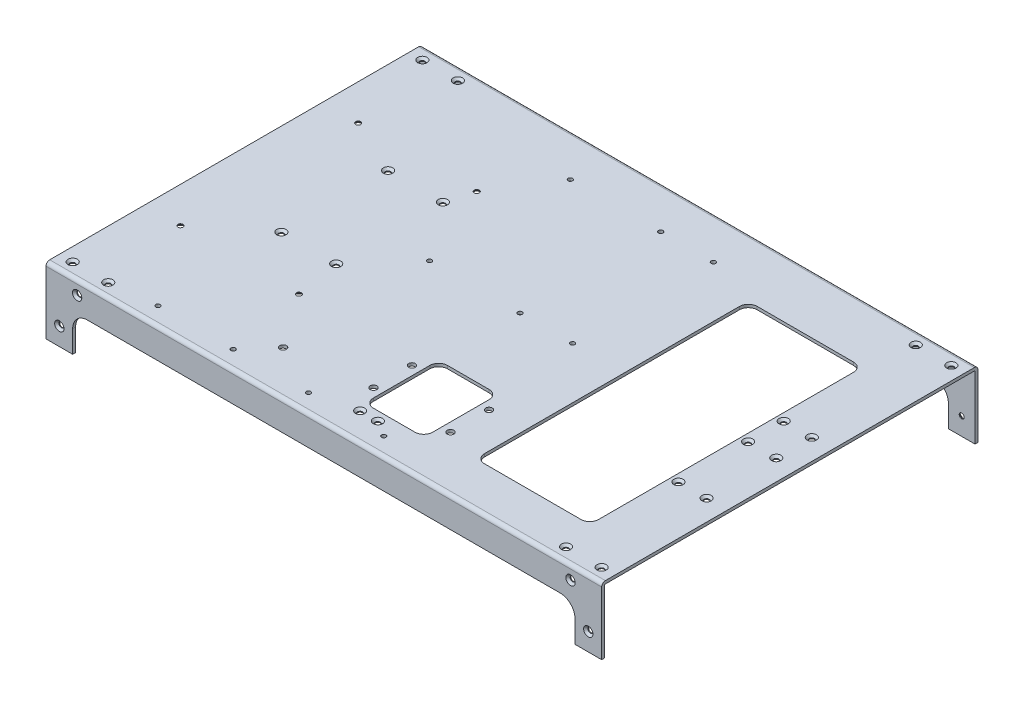
from build123d import *

# Parameters (mm, degrees)
BOSS_EXTRUDE1_DEPTH                             = 187.5
CUT_EXTRUDE1_DEPTH                              = 255
CUT_EXTRUDE4_DEPTH                              = 10
SKETCH6_R                                       = 1.5
CUT_EXTRUDE5_DEPTH                              = 255
SKETCH9_R                                       = 1.5
CUT_EXTRUDE8_DEPTH                              = 10
SKETCH19_R                                      = 1.5
CUT_EXTRUDE9_DEPTH                              = 10
SKETCH20_R                                      = 1.75
CUT_EXTRUDE10_DEPTH                             = 10
CSK_FOR_M3_FLAT_HEAD_MACHINE_SCREW1_D           = 3.4
CSK_FOR_M3_FLAT_HEAD_MACHINE_SCREW1_DEPTH       = 10
CSK_FOR_M3_FLAT_HEAD_MACHINE_SCREW1_CSINK_D     = 6.3
CSK_FOR_M3_FLAT_HEAD_MACHINE_SCREW1_CSINK_ANGLE = 90
CSK_FOR_M3_FLAT_HEAD_MACHINE_SCREW1_TIP         = 1.021463052
CSK_FOR_M3_FLAT_HEAD_MACHINE_SCREW2_D           = 3.4
CSK_FOR_M3_FLAT_HEAD_MACHINE_SCREW2_DEPTH       = 10
CSK_FOR_M3_FLAT_HEAD_MACHINE_SCREW2_CSINK_D     = 6.3
CSK_FOR_M3_FLAT_HEAD_MACHINE_SCREW2_CSINK_ANGLE = 90
CSK_FOR_M3_FLAT_HEAD_MACHINE_SCREW2_TIP         = 1.021463052
CSK_FOR_M3_FLAT_HEAD_MACHINE_SCREW3_D           = 3.4
CSK_FOR_M3_FLAT_HEAD_MACHINE_SCREW3_DEPTH       = 10
CSK_FOR_M3_FLAT_HEAD_MACHINE_SCREW3_CSINK_D     = 6.3
CSK_FOR_M3_FLAT_HEAD_MACHINE_SCREW3_CSINK_ANGLE = 90
CSK_FOR_M3_FLAT_HEAD_MACHINE_SCREW3_TIP         = 1.021463052
SKETCH28_R                                      = 2.25
CUT_EXTRUDE11_DEPTH                             = 10
CSK_FOR_M3_FLAT_HEAD_MACHINE_SCREW4_D           = 3.4
CSK_FOR_M3_FLAT_HEAD_MACHINE_SCREW4_DEPTH       = 10
CSK_FOR_M3_FLAT_HEAD_MACHINE_SCREW4_CSINK_D     = 6.3
CSK_FOR_M3_FLAT_HEAD_MACHINE_SCREW4_CSINK_ANGLE = 90
CSK_FOR_M3_FLAT_HEAD_MACHINE_SCREW4_TIP         = 1.021463052
SKETCH31_R                                      = 2.25
SKETCH31_R_2                                    = 1.5
CUT_EXTRUDE12_DEPTH                             = 10
CSK_FOR_M3_FLAT_HEAD_MACHINE_SCREW5_D           = 3.4
CSK_FOR_M3_FLAT_HEAD_MACHINE_SCREW5_DEPTH       = 10
CSK_FOR_M3_FLAT_HEAD_MACHINE_SCREW5_CSINK_D     = 6.3
CSK_FOR_M3_FLAT_HEAD_MACHINE_SCREW5_CSINK_ANGLE = 90
CSK_FOR_M3_FLAT_HEAD_MACHINE_SCREW5_TIP         = 1.021463052


with BuildPart() as part:
    # Sketch1 → Boss-Extrude1 (new body, symmetric)
    with BuildSketch(Plane(origin=(0, 0, 0), x_dir=(0, 0, -1), z_dir=(1, 0, 0))):
        with BuildLine():
            Line((125, -100.5), (127, -100.5))
            Line((127, -100.5), (127, -2.5))
            ThreePointArc((127, -2.5), (126.267766953, -0.732233047), (124.5, 0))
            Line((124.5, 0), (-124.5, 0))
            ThreePointArc((-124.5, 0), (-126.267766953, -0.732233047), (-127, -2.5))
            Line((-127, -2.5), (-127, -100.5))
            Line((-127, -100.5), (-125, -100.5))
            Line((-125, -100.5), (-125, -2.5))
            ThreePointArc((-125, -2.5), (-124.853553391, -2.146446609), (-124.5, -2))
            Line((-124.5, -2), (124.5, -2))
            ThreePointArc((124.5, -2), (124.853553391, -2.146446609), (125, -2.5))
            Line((125, -2.5), (125, -100.5))
        make_face()
    extrude(amount=BOSS_EXTRUDE1_DEPTH, both=True)

    # Sketch2 → Cut-Extrude1 (cut, through all)
    with BuildSketch(Plane.XY.offset(127)):
        with BuildLine():
            Line((187.5, -45), (187.5, -100.5))
            Line((187.5, -100.5), (-187.5, -100.5))
            Line((-187.5, -100.5), (-187.5, -45))
            Line((-187.5, -45), (-169.5, -45))
            Line((-169.5, -45), (-169.5, -30))
            ThreePointArc((-169.5, -30), (-166.571067812, -22.928932188), (-159.5, -20))
            Line((-159.5, -20), (159.5, -20))
            ThreePointArc((159.5, -20), (166.571067812, -22.928932188), (169.5, -30))
            Line((169.5, -30), (169.5, -45))
            Line((169.5, -45), (187.5, -45))
        make_face()
    extrude(amount=-CUT_EXTRUDE1_DEPTH, mode=Mode.SUBTRACT)

    # Sketch5 → Cut-Extrude4 (cut)
    with BuildSketch(Plane.XZ.offset(2)):
        with BuildLine():
            Line((78.5, 97), (143.5, 97))
            ThreePointArc((143.5, 97), (147.742640687, 95.242640687), (149.5, 91))
            Line((149.5, 91), (149.5, -81))
            ThreePointArc((149.5, -81), (147.742640687, -85.242640687), (143.5, -87))
            Line((143.5, -87), (78.5, -87))
            ThreePointArc((78.5, -87), (74.257359313, -85.242640687), (72.5, -81))
            Line((72.5, -81), (72.5, 91))
            ThreePointArc((72.5, 91), (74.257359313, 95.242640687), (78.5, 97))
        make_face()
    extrude(amount=-CUT_EXTRUDE4_DEPTH, mode=Mode.SUBTRACT)

    # Sketch6 → Cut-Extrude5 (cut, through all)
    with BuildSketch(Plane(origin=(0, 0, -127), x_dir=(-1, 0, 0), z_dir=(0, 0, -1))):
        with Locations((-178.5, -33)):
            Circle(SKETCH6_R)
        with Locations((-166.5, -9)):
            Circle(SKETCH6_R)
        with Locations((166.5, -9)):
            Circle(SKETCH6_R)
        with Locations((178.5, -33)):
            Circle(SKETCH6_R)
    extrude(amount=-CUT_EXTRUDE5_DEPTH, mode=Mode.SUBTRACT)

    # Sketch9 → Cut-Extrude8 (cut)
    with BuildSketch(Plane(origin=(0, 0, 0), x_dir=(1, 0, 0), z_dir=(0, 1, 0))):
        with Locations(Location((-178.5, 118, 0), (0, 0, 270))):  # turned: the seam where the file's is
            Circle(SKETCH9_R)
        with Locations(Location((-154.5, 118, 0), (0, 0, 270))):  # turned: the seam where the file's is
            Circle(SKETCH9_R)
        with Locations(Location((154.5, 118, 0), (0, 0, 270))):  # turned: the seam where the file's is
            Circle(SKETCH9_R)
        with Locations(Location((178.5, 118, 0), (0, 0, 270))):  # turned: the seam where the file's is
            Circle(SKETCH9_R)
        with Locations(Location((178.5, -118, 0), (0, 0, 270))):  # turned: the seam where the file's is
            Circle(SKETCH9_R)
        with Locations(Location((154.5, -118, 0), (0, 0, 270))):  # turned: the seam where the file's is
            Circle(SKETCH9_R)
        with Locations(Location((-154.5, -118, 0), (0, 0, 270))):  # turned: the seam where the file's is
            Circle(SKETCH9_R)
        with Locations(Location((-178.5, -118, 0), (0, 0, 270))):  # turned: the seam where the file's is
            Circle(SKETCH9_R)
        with Locations(Location((-125.5, 41.85, 0), (0, 0, 270))):  # turned: the seam where the file's is
            Circle(SKETCH9_R)
        with Locations(Location((-88.5, 41.85, 0), (0, 0, 270))):  # turned: the seam where the file's is
            Circle(SKETCH9_R)
        with Locations(Location((-125.5, -30.15, 0), (0, 0, 270))):  # turned: the seam where the file's is
            Circle(SKETCH9_R)
        with Locations(Location((-88.5, -30.15, 0), (0, 0, 270))):  # turned: the seam where the file's is
            Circle(SKETCH9_R)
        with Locations(Location((154.5, 28.85, 0), (0, 0, 270))):  # turned: the seam where the file's is
            Circle(SKETCH9_R)
        with Locations(Location((173.5, 4.85, 0), (0, 0, 270))):  # turned: the seam where the file's is
            Circle(SKETCH9_R)
        with Locations(Location((154.5, 4.85, 0), (0, 0, 270))):  # turned: the seam where the file's is
            Circle(SKETCH9_R)
        with Locations(Location((173.5, 28.85, 0), (0, 0, 270))):  # turned: the seam where the file's is
            Circle(SKETCH9_R)
        with Locations(Location((154.5, -42.15, 0), (0, 0, 270))):  # turned: the seam where the file's is
            Circle(SKETCH9_R)
        with Locations(Location((173.5, -42.15, 0), (0, 0, 270))):  # turned: the seam where the file's is
            Circle(SKETCH9_R)
    extrude(amount=-CUT_EXTRUDE8_DEPTH, mode=Mode.SUBTRACT)

    # Sketch19 → Cut-Extrude9 (cut)
    with BuildSketch(Plane(origin=(0, 0, 0), x_dir=(1, 0, 0), z_dir=(0, 1, 0))):
        with Locations(Location((2.31, 98.065, 0), (0, 0, 270))):  # turned: the seam where the file's is
            Circle(SKETCH19_R)
        with Locations(Location((-58.69, 98.065, 0), (0, 0, 270))):  # turned: the seam where the file's is
            Circle(SKETCH19_R)
        with Locations(Location((37.83, 98.065, 0), (0, 0, 270))):  # turned: the seam where the file's is
            Circle(SKETCH19_R)
        with Locations(Location((-58.69, 3.065, 0), (0, 0, 270))):  # turned: the seam where the file's is
            Circle(SKETCH19_R)
        with Locations(Location((37.83, 3.065, 0), (0, 0, 270))):  # turned: the seam where the file's is
            Circle(SKETCH19_R)
        with Locations(Location((2.31, 3.065, 0), (0, 0, 270))):  # turned: the seam where the file's is
            Circle(SKETCH19_R)
        with Locations(Location((-163.3, 59.5, 0), (0, 0, 270))):  # turned: the seam where the file's is
            Circle(SKETCH19_R)
        with Locations(Location((-163.3, -60.5, 0), (0, 0, 270))):  # turned: the seam where the file's is
            Circle(SKETCH19_R)
        with Locations(Location((-83.3, -60.5, 0), (0, 0, 270))):  # turned: the seam where the file's is
            Circle(SKETCH19_R)
        with Locations(Location((-83.3, 59.5, 0), (0, 0, 270))):  # turned: the seam where the file's is
            Circle(SKETCH19_R)
        with Locations(Location((-124.1, -114.8527, 0), (0, 0, 270))):  # turned: the seam where the file's is
            Circle(SKETCH19_R)
        with Locations(Location((-73.3, -114.8527, 0), (0, 0, 270))):  # turned: the seam where the file's is
            Circle(SKETCH19_R)
        with Locations(Location((-22.5, -114.8527, 0), (0, 0, 270))):  # turned: the seam where the file's is
            Circle(SKETCH19_R)
        with Locations(Location((28.3, -114.8527, 0), (0, 0, 270))):  # turned: the seam where the file's is
            Circle(SKETCH19_R)
    extrude(amount=-CUT_EXTRUDE9_DEPTH, mode=Mode.SUBTRACT)

    # Sketch20 → Cut-Extrude10 (cut)
    with BuildSketch(Plane(origin=(0, 0, -127), x_dir=(-1, 0, 0), z_dir=(0, 0, -1))):
        with Locations((-39.5, -8)):
            Circle(SKETCH20_R)
        with Locations((47.5, -8)):
            Circle(SKETCH20_R)
        with Locations((134.5, -8)):
            Circle(SKETCH20_R)
    extrude(amount=-CUT_EXTRUDE10_DEPTH, mode=Mode.SUBTRACT)

    # CSK for M3 Flat Head Machine Screw1
    with Locations(Plane.XY.offset(127)):
        with Locations((-166.5, -9), (166.5, -9), (178.5, -33), (-178.5, -33)):
            CounterSinkHole(CSK_FOR_M3_FLAT_HEAD_MACHINE_SCREW1_D / 2, CSK_FOR_M3_FLAT_HEAD_MACHINE_SCREW1_CSINK_D / 2, depth=CSK_FOR_M3_FLAT_HEAD_MACHINE_SCREW1_DEPTH, counter_sink_angle=CSK_FOR_M3_FLAT_HEAD_MACHINE_SCREW1_CSINK_ANGLE)
            with Locations((0, 0, -(CSK_FOR_M3_FLAT_HEAD_MACHINE_SCREW1_DEPTH + CSK_FOR_M3_FLAT_HEAD_MACHINE_SCREW1_TIP / 2))):  # 118° drill point
                Cone(0, CSK_FOR_M3_FLAT_HEAD_MACHINE_SCREW1_D / 2, CSK_FOR_M3_FLAT_HEAD_MACHINE_SCREW1_TIP, mode=Mode.SUBTRACT)

    # CSK for M3 Flat Head Machine Screw2
    with Locations(Plane(origin=(0, 0, -127), x_dir=(-1, 0, 0), z_dir=(0, 0, -1))):
        with Locations((-166.5, -9), (178.5, -33), (166.5, -9), (-178.5, -33)):
            CounterSinkHole(CSK_FOR_M3_FLAT_HEAD_MACHINE_SCREW2_D / 2, CSK_FOR_M3_FLAT_HEAD_MACHINE_SCREW2_CSINK_D / 2, depth=CSK_FOR_M3_FLAT_HEAD_MACHINE_SCREW2_DEPTH, counter_sink_angle=CSK_FOR_M3_FLAT_HEAD_MACHINE_SCREW2_CSINK_ANGLE)
            with Locations((0, 0, -(CSK_FOR_M3_FLAT_HEAD_MACHINE_SCREW2_DEPTH + CSK_FOR_M3_FLAT_HEAD_MACHINE_SCREW2_TIP / 2))):  # 118° drill point
                Cone(0, CSK_FOR_M3_FLAT_HEAD_MACHINE_SCREW2_D / 2, CSK_FOR_M3_FLAT_HEAD_MACHINE_SCREW2_TIP, mode=Mode.SUBTRACT)

    # CSK for M3 Flat Head Machine Screw3
    with Locations(Plane(origin=(0, 0, 0), x_dir=(-1, 0, 0), z_dir=(0, 1, 0))):
        with Locations((88.5, -41.85), (178.5, -118), (154.5, -118), (125.5, -41.85), (125.5, 30.15), (88.5, 30.15), (178.5, 118), (154.5, 118), (-154.5, 118), (-178.5, 118), (-154.5, 42.15), (-173.5, 42.15), (-173.5, -4.85), (-154.5, -4.85), (-173.5, -28.85), (-154.5, -28.85), (-178.5, -118), (-154.5, -118)):
            CounterSinkHole(CSK_FOR_M3_FLAT_HEAD_MACHINE_SCREW3_D / 2, CSK_FOR_M3_FLAT_HEAD_MACHINE_SCREW3_CSINK_D / 2, depth=CSK_FOR_M3_FLAT_HEAD_MACHINE_SCREW3_DEPTH, counter_sink_angle=CSK_FOR_M3_FLAT_HEAD_MACHINE_SCREW3_CSINK_ANGLE)
            with Locations((0, 0, -(CSK_FOR_M3_FLAT_HEAD_MACHINE_SCREW3_DEPTH + CSK_FOR_M3_FLAT_HEAD_MACHINE_SCREW3_TIP / 2))):  # 118° drill point
                Cone(0, CSK_FOR_M3_FLAT_HEAD_MACHINE_SCREW3_D / 2, CSK_FOR_M3_FLAT_HEAD_MACHINE_SCREW3_TIP, mode=Mode.SUBTRACT)

    # Sketch28 → Cut-Extrude11 (cut)
    with BuildSketch(Plane(origin=(0, 0, 0), x_dir=(-1, 0, 0), z_dir=(0, 1, 0))):
        with Locations(Location((57.5, 97, 0), (0, 0, 90))):  # turned: the seam where the file's is
            Circle(SKETCH28_R)
        with BuildLine():
            Line((-8.5, 52), (-36.5, 52))
            ThreePointArc((-36.5, 52), (-40.742640687, 53.757359313), (-42.5, 58))
            Line((-42.5, 58), (-42.5, 96))
            ThreePointArc((-42.5, 96), (-40.742640687, 100.242640687), (-36.5, 102))
            Line((-36.5, 102), (-8.5, 102))
            ThreePointArc((-8.5, 102), (-4.257359313, 100.242640687), (-2.5, 96))
            Line((-2.5, 96), (-2.5, 58))
            ThreePointArc((-2.5, 58), (-4.257359313, 53.757359313), (-8.5, 52))
        make_face()
    extrude(amount=-CUT_EXTRUDE11_DEPTH, mode=Mode.SUBTRACT)

    # CSK for M3 Flat Head Machine Screw4
    with Locations(Plane.XZ.offset(2)):
        with Locations((-163.3, -59.5), (-163.3, 60.5), (-83.3, 60.5), (-83.3, -59.5)):
            CounterSinkHole(CSK_FOR_M3_FLAT_HEAD_MACHINE_SCREW4_D / 2, CSK_FOR_M3_FLAT_HEAD_MACHINE_SCREW4_CSINK_D / 2, depth=CSK_FOR_M3_FLAT_HEAD_MACHINE_SCREW4_DEPTH, counter_sink_angle=CSK_FOR_M3_FLAT_HEAD_MACHINE_SCREW4_CSINK_ANGLE)
            with Locations((0, 0, -(CSK_FOR_M3_FLAT_HEAD_MACHINE_SCREW4_DEPTH + CSK_FOR_M3_FLAT_HEAD_MACHINE_SCREW4_TIP / 2))):  # 118° drill point
                Cone(0, CSK_FOR_M3_FLAT_HEAD_MACHINE_SCREW4_D / 2, CSK_FOR_M3_FLAT_HEAD_MACHINE_SCREW4_TIP, mode=Mode.SUBTRACT)

    # Sketch31 → Cut-Extrude12 (cut)
    with BuildSketch(Plane(origin=(0, 0, 0), x_dir=(1, 0, 0), z_dir=(0, 1, 0))):
        with Locations(Location((-3.5, -64, 0), (0, 0, 270))):  # turned: the seam where the file's is
            Circle(SKETCH31_R)
        with Locations(Location((-3.5, -90, 0), (0, 0, 270))):  # turned: the seam where the file's is
            Circle(SKETCH31_R)
        with Locations(Location((48.5, -64, 0), (0, 0, 270))):  # turned: the seam where the file's is
            Circle(SKETCH31_R)
        with Locations(Location((48.5, -90, 0), (0, 0, 270))):  # turned: the seam where the file's is
            Circle(SKETCH31_R)
        with Locations(Location((17.5, -108, 0), (0, 0, 270))):  # turned: the seam where the file's is
            Circle(SKETCH31_R_2)
        with Locations(Location((5.5, -108, 0), (0, 0, 270))):  # turned: the seam where the file's is
            Circle(SKETCH31_R_2)
    extrude(amount=-CUT_EXTRUDE12_DEPTH, mode=Mode.SUBTRACT)

    # CSK for M3 Flat Head Machine Screw5
    with Locations(Plane(origin=(0, 0, 0), x_dir=(-1, 0, 0), z_dir=(0, 1, 0))):
        with Locations((-5.5, 108), (-17.5, 108)):
            CounterSinkHole(CSK_FOR_M3_FLAT_HEAD_MACHINE_SCREW5_D / 2, CSK_FOR_M3_FLAT_HEAD_MACHINE_SCREW5_CSINK_D / 2, depth=CSK_FOR_M3_FLAT_HEAD_MACHINE_SCREW5_DEPTH, counter_sink_angle=CSK_FOR_M3_FLAT_HEAD_MACHINE_SCREW5_CSINK_ANGLE)
            with Locations((0, 0, -(CSK_FOR_M3_FLAT_HEAD_MACHINE_SCREW5_DEPTH + CSK_FOR_M3_FLAT_HEAD_MACHINE_SCREW5_TIP / 2))):  # 118° drill point
                Cone(0, CSK_FOR_M3_FLAT_HEAD_MACHINE_SCREW5_D / 2, CSK_FOR_M3_FLAT_HEAD_MACHINE_SCREW5_TIP, mode=Mode.SUBTRACT)


solid = part.part
